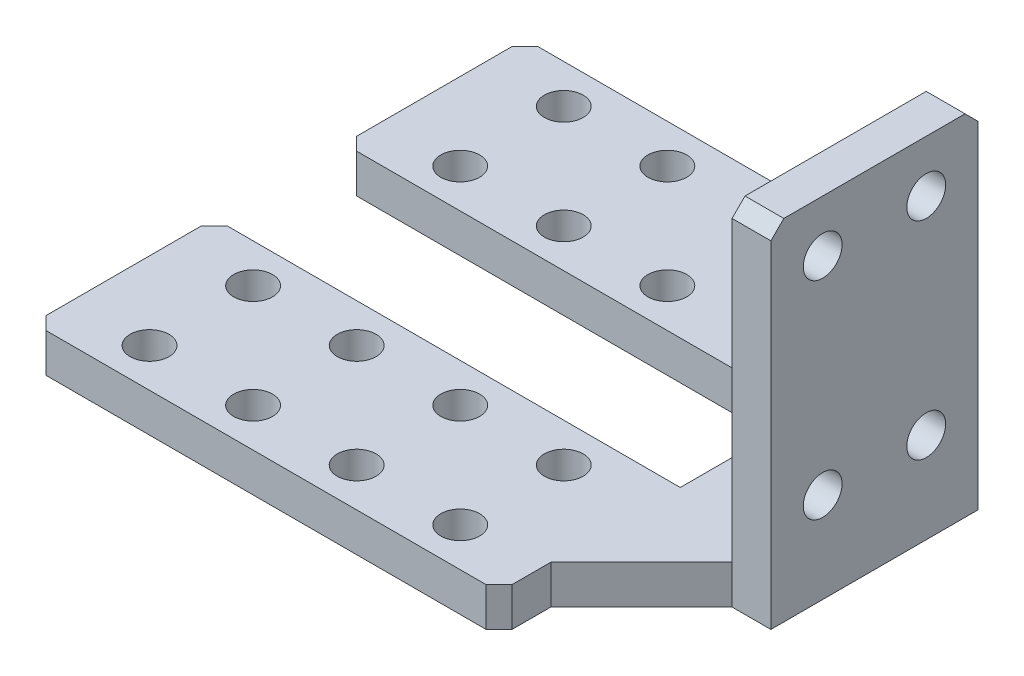
from build123d import *

# Parameters (mm, degrees)
SKETCH_1_W          = 3
SKETCH_1_H          = 24
EXTRUDE_1_DEPTH     = 16
SKETCH_2_R          = 1.5
CUT_EXTRUDE_1_DEPTH = 16
CHAMFER_1_SIZE      = 1
SKETCH_3_W          = 16
SKETCH_3_H          = 3
EXTRUDE_2_DEPTH     = 10
EXTRUDE_3_DEPTH     = 3
CHAMFER_2_SIZE      = 1
SKETCH_5_R          = 1.5
CUT_EXTRUDE_2_DEPTH = 10
CHAMFER_3_SIZE      = 7


with BuildPart() as part:
    # 草图1 → 凸台-拉伸1 (new body)
    with BuildSketch(Plane.XY):
        with Locations((-1.5, 12)):
            Rectangle(SKETCH_1_W, SKETCH_1_H)
    extrude(amount=EXTRUDE_1_DEPTH)

    # 草图2 → 切除-拉伸1 (cut)
    with BuildSketch(Plane.ZY.offset(3)):
        with Locations((4, 4)):
            Circle(SKETCH_2_R)
        with Locations((12, 4)):
            Circle(SKETCH_2_R)
        with Locations((4, 20)):
            Circle(SKETCH_2_R)
        with Locations((12, 20)):
            Circle(SKETCH_2_R)
    extrude(amount=-CUT_EXTRUDE_1_DEPTH, mode=Mode.SUBTRACT)

    # 倒角1
    chamfer_1_edges = [part.edges().sort_by_distance(p)[0] for p in [
        (-1.5, 24, 0),
        (-1.5, 24, 16),
    ]]
    chamfer(chamfer_1_edges, length=CHAMFER_1_SIZE)

    # 草图3 → 凸台-拉伸2 (add)
    with BuildSketch(Plane(origin=(0, 0, 0), x_dir=(0, 0, -1), z_dir=(1, 0, 0))):
        with Locations((-8, -1.5)):
            Rectangle(SKETCH_3_W, SKETCH_3_H)
    extrude(amount=-EXTRUDE_2_DEPTH)

    # 草图4 → 凸台-拉伸3 (add)
    with BuildSketch(Plane(origin=(0, 0, 0), x_dir=(1, 0, 0), z_dir=(0, 1, 0))):
        Polygon((-10, 11), (-46, 11), (-46, -3), (-10, -3), (-10, 0), align=None)
        Polygon((-10, -16), (-10, -13), (-46, -13), (-46, -27), (-10, -27), align=None)
    extrude(amount=-EXTRUDE_3_DEPTH)

    # 倒角2
    chamfer_2_edges = [part.edges().sort_by_distance(p)[0] for p in [
        (-46, -1.5, 3),
        (-46, -1.5, -11),
        (-10, -1.5, -11),
        (-46, -1.5, 27),
        (-10, -1.5, 27),
        (-46, -1.5, 13),
    ]]
    chamfer(chamfer_2_edges, length=CHAMFER_2_SIZE)

    # 草图5 → 切除-拉伸2 (cut)
    with BuildSketch(Plane(origin=(0, 0, 0), x_dir=(1, 0, 0), z_dir=(0, 1, 0))):
        with Locations((-40, 8)):
            Circle(SKETCH_5_R)
        with Locations((-32, 8)):
            Circle(SKETCH_5_R)
        with Locations((-24, 8)):
            Circle(SKETCH_5_R)
        with Locations((-16, 8)):
            Circle(SKETCH_5_R)
        with Locations((-40, 0)):
            Circle(SKETCH_5_R)
        with Locations((-32, 0)):
            Circle(SKETCH_5_R)
        with Locations((-24, 0)):
            Circle(SKETCH_5_R)
        with Locations((-16, 0)):
            Circle(SKETCH_5_R)
        with Locations((-40, -16)):
            Circle(SKETCH_5_R)
        with Locations((-40, -24)):
            Circle(SKETCH_5_R)
        with Locations((-32, -16)):
            Circle(SKETCH_5_R)
        with Locations((-32, -24)):
            Circle(SKETCH_5_R)
        with Locations((-24, -16)):
            Circle(SKETCH_5_R)
        with Locations((-24, -24)):
            Circle(SKETCH_5_R)
        with Locations((-16, -16)):
            Circle(SKETCH_5_R)
        with Locations((-16, -24)):
            Circle(SKETCH_5_R)
    extrude(amount=-CUT_EXTRUDE_2_DEPTH, mode=Mode.SUBTRACT)

    # 倒角3
    chamfer_3_edges = [part.edges().sort_by_distance(p)[0] for p in [
        (-10, -1.5, 16),
        (-10, -1.5, 0),
    ]]
    chamfer(chamfer_3_edges, length=CHAMFER_3_SIZE)


solid = part.part
